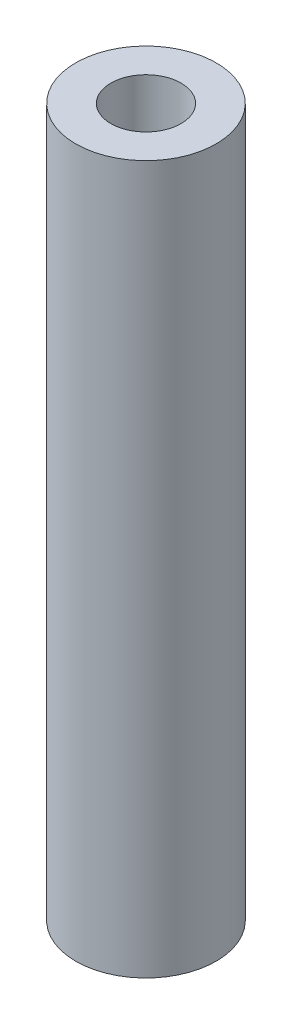
from build123d import *

# Parameters (mm, degrees)
SKETCH1_R           = 6.35
SKETCH1_R_2         = 3.175
BOSS_EXTRUDE1_DEPTH = 63.99784


with BuildPart() as part:
    # Sketch1 → Boss-Extrude1 (new body)
    with BuildSketch(Plane(origin=(0, 0, 0), x_dir=(1, 0, 0), z_dir=(0, 1, 0))):
        Circle(SKETCH1_R)
        Circle(SKETCH1_R_2, mode=Mode.SUBTRACT)
    extrude(amount=BOSS_EXTRUDE1_DEPTH)


solid = part.part
